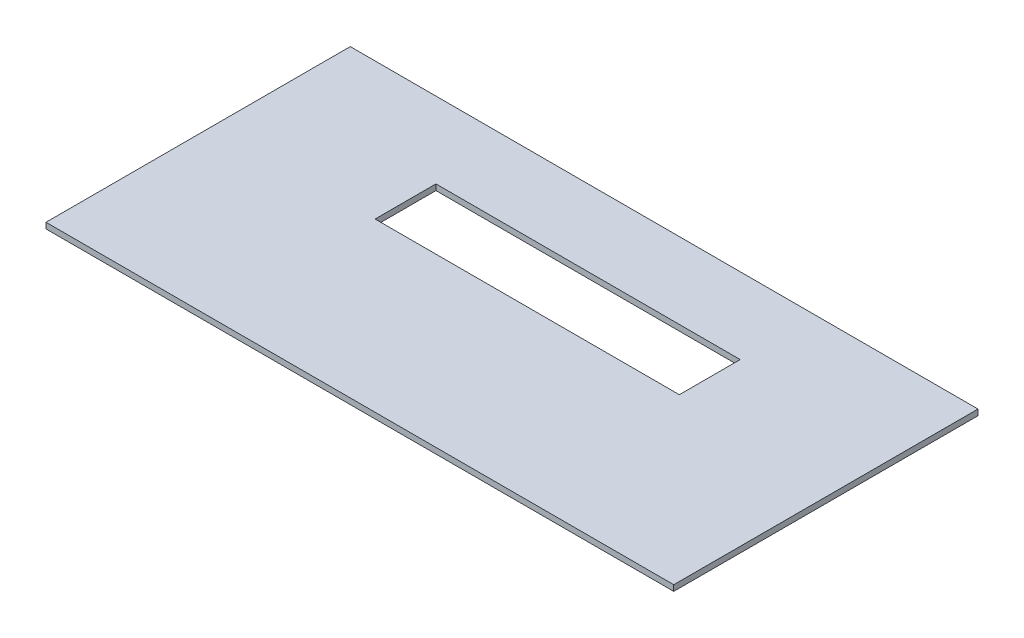
from build123d import *

# Parameters (mm, degrees)
SKETCH1_W           = 131.01574
SKETCH1_H           = 63.5
BOSS_EXTRUDE1_DEPTH = 1.21412
SKETCH2_W           = 63.5
SKETCH2_H           = 12.7
CUT_EXTRUDE1_DEPTH  = 2.21412


with BuildPart() as part:
    # Sketch1 → Boss-Extrude1 (new body)
    with BuildSketch(Plane(origin=(0, 0, 0), x_dir=(1, 0, 0), z_dir=(0, 1, 0))):
        Rectangle(SKETCH1_W, SKETCH1_H)
    extrude(amount=BOSS_EXTRUDE1_DEPTH)

    # Sketch2 → Cut-Extrude1 (cut, through all)
    with BuildSketch(Plane(origin=(0, 1.21412, 0), x_dir=(1, 0, 0), z_dir=(0, 1, 0))):
        with Locations((0, 9.525)):
            Rectangle(SKETCH2_W, SKETCH2_H)
    extrude(amount=-CUT_EXTRUDE1_DEPTH, mode=Mode.SUBTRACT)


solid = part.part
